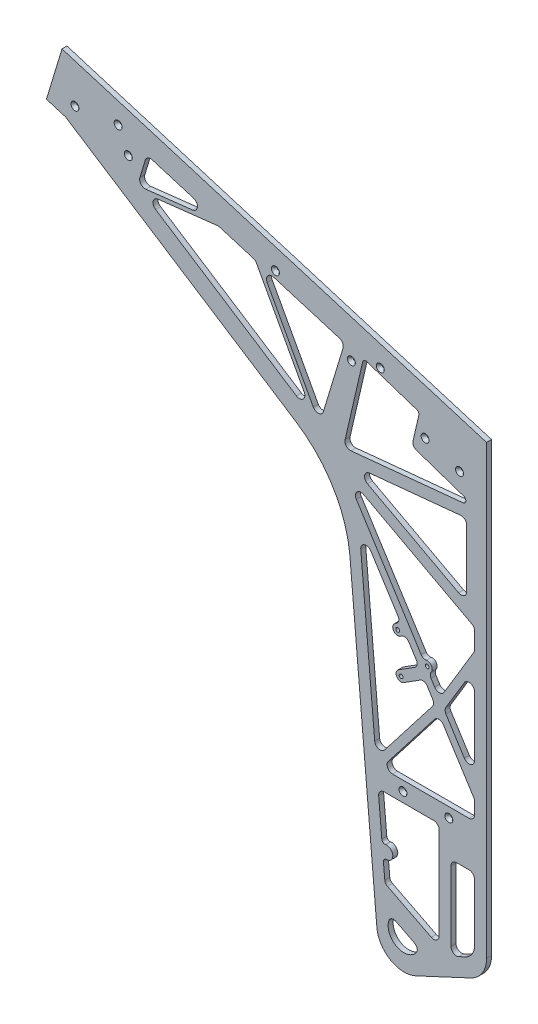
from build123d import *

# Parameters (mm, degrees)
BOSS_EXTRUDE1_DEPTH       = 6.35
BOSS_EXTRUDE3_DEPTH       = 6.35
FILLET2_R                 = 6.35
F_8_CLEARANCE_HOLE1_D     = 4.9149
F_8_CLEARANCE_HOLE1_DEPTH = 6.35
HOLE1_D                   = 3.175
HOLE1_DEPTH               = 31.75
HOLE1_CSINK_D             = 10.16
HOLE1_CSINK_ANGLE         = 82
HOLE1_TIP                 = 0.953866233


with BuildPart() as part:
    # Sketch2 → Boss-Extrude1 (new body)
    with BuildSketch(Plane.XY):
        with BuildLine():
            Line((-35.929687435, 42.153790719), (-1.51387348, -351.220762831))
            ThreePointArc((-1.51387348, -351.220762831), (15.815726351, -378.422785743), (48.038169143, -379.829647978))
            Line((48.038169143, -379.829647978), (118.213861049, -347.106185426))
            ThreePointArc((118.213861049, -347.106185426), (132.909364503, -334.218574785), (138.378918258, -315.453385964))
            Line((138.378918258, -315.453385964), (138.378918258, 254.538122714))
            Line((138.378918258, 254.538122714), (-403.099057101, 418.419278389))
            Line((-403.099057101, 418.419278389), (-422.935039487, 352.879420939))
            Line((-422.935039487, 352.879420939), (-398.624090476, 345.521584423))
            Line((-398.624090476, 345.521584423), (-105.026598758, 156.030008008))
            ThreePointArc((-105.026598758, 156.030008008), (-57.378429325, 107.040440177), (-35.929687435, 42.153790719))
        make_face()
        with BuildLine():
            Line((52.060968117, -347.265819105), (17.052845203, -329.494257158))
            ThreePointArc((17.052845203, -329.494257158), (23.771187013, -359.626780553), (52.060968117, -347.265819105))
        make_face(mode=Mode.SUBTRACT)
        with BuildLine():
            Line((0.727528104, -204.399467425), (4.75858829, -250.474696191))
            ThreePointArc((4.75858829, -250.474696191), (6.172216644, -253.190250993), (9.091990054, -254.110852012))
            Line((9.091990054, -254.110852012), (10.088184752, -254.02369627))
            ThreePointArc((10.088184752, -254.02369627), (18.754988278, -261.296007912), (11.482676636, -269.962811439))
            Line((11.482676636, -269.962811439), (10.486481938, -270.049967182))
            ThreePointArc((10.486481938, -270.049967182), (7.770927136, -271.463595536), (6.850326116, -274.383368945))
            Line((6.850326116, -274.383368945), (8.854908199, -297.295847001))
            Line((8.854908199, -297.295847001), (67.831407622, -327.234741912))
            ThreePointArc((67.831407622, -327.234741912), (74.661956673, -326.958687149), (78, -320.992945508))
            Line((78, -320.992945508), (78, -203.789377226))
            ThreePointArc((78, -203.789377226), (75.949747468, -198.839629758), (71, -196.789377226))
            Line((71, -196.789377226), (7.70089099, -196.789377226))
            ThreePointArc((7.70089099, -196.789377226), (2.539949633, -199.060245773), (0.727528104, -204.399467425))
        make_face(mode=Mode.SUBTRACT)
        with BuildLine():
            Line((123, -309.069613992), (123, -235.789377226))
            ThreePointArc((123, -235.789377226), (120.949747468, -230.839629758), (116, -228.789377226))
            Line((116, -228.789377226), (100, -228.789377226))
            ThreePointArc((100, -228.789377226), (95.050252532, -230.839629758), (93, -235.789377226))
            Line((93, -235.789377226), (93, -324.812449913))
            ThreePointArc((93, -324.812449913), (96.238902742, -330.716190033), (102.958327832, -331.156604422))
            Line((102.958327832, -331.156604422), (111.452365235, -327.195769732))
            ThreePointArc((111.452365235, -327.195769732), (119.867828916, -319.815606158), (123, -309.069613992))
        make_face(mode=Mode.SUBTRACT)
        with BuildLine():
            Line((123, -164.789377226), (123, -147.490950451))
            Line((123, -147.490950451), (83.358453873, -85.049471439))
            ThreePointArc((83.358453873, -85.049471439), (77.778314801, -81.809029579), (71.918165908, -84.510338605))
            Line((71.918165908, -84.510338605), (12.96294892, -160.498446277))
            ThreePointArc((12.96294892, -160.498446277), (12.207227911, -167.868620912), (18.493582843, -171.789377226))
            Line((18.493582843, -171.789377226), (116, -171.789377226))
            ThreePointArc((116, -171.789377226), (120.949747468, -169.739124694), (123, -164.789377226))
        make_face(mode=Mode.SUBTRACT)
        with BuildLine():
            Line((123, -104.746758641), (123, -28.654884494))
            ThreePointArc((123, -28.654884494), (117.87337083, -21.91022129), (110.002719505, -25.044811549))
            Line((110.002719505, -25.044811549), (86.491561629, -64.103027464))
            ThreePointArc((86.491561629, -64.103027464), (85.489337935, -67.796413702), (86.579188082, -71.464898525))
            Line((86.579188082, -71.464898525), (110.090345958, -108.498556757))
            ThreePointArc((110.090345958, -108.498556757), (117.95351244, -111.468647449), (123, -104.746758641))
        make_face(mode=Mode.SUBTRACT)
        with BuildLine():
            Line((-22.088705619, 56.391277374), (-4.323316108, -146.668053908))
            ThreePointArc((-4.323316108, -146.668053908), (0.673303529, -152.773057612), (8.180680701, -150.348894658))
            Line((8.180680701, -150.348894658), (69.309232347, -71.559549091))
            ThreePointArc((69.309232347, -71.559549091), (70.770838401, -67.598133112), (69.688252467, -63.516820026))
            Line((69.688252467, -63.516820026), (-9.20568869, 60.753165689))
            ThreePointArc((-9.20568869, 60.753165689), (-17.360200533, 63.631647617), (-22.088705619, 56.391277374))
        make_face(mode=Mode.SUBTRACT)
        with BuildLine():
            Line((84.107110781, -48.674037444), (123, 15.937279137))
            Line((123, 15.937279137), (123, 42.734746572))
            Line((123, 42.734746572), (-18.511705321, 118.505409967))
            ThreePointArc((-18.511705321, 118.505409967), (-26.945537791, 117.097436807), (-27.725581647, 108.582541028))
            Line((-27.725581647, 108.582541028), (72.200176244, -48.815762615))
            ThreePointArc((72.200176244, -48.815762615), (78.193143579, -52.063468688), (84.107110781, -48.674037444))
        make_face(mode=Mode.SUBTRACT)
        with BuildLine():
            Line((105.313578156, 157.453539643), (-10.929529426, 145.999506934))
            ThreePointArc((-10.929529426, 145.999506934), (-17.10814199, 140.401199203), (-13.547329865, 132.862172762))
            Line((-13.547329865, 132.862172762), (102.695777716, 70.621262326))
            ThreePointArc((102.695777716, 70.621262326), (109.596556966, 70.786937409), (113, 76.792333148))
            Line((113, 76.792333148), (113, 150.487276294))
            ThreePointArc((113, 150.487276294), (110.700800309, 155.67403602), (105.313578156, 157.453539643))
        make_face(mode=Mode.SUBTRACT)
        with BuildLine():
            Line((49.392848873, 246.173011312), (-14.483251541, 267.337792758))
            ThreePointArc((-14.483251541, 267.337792758), (-17.700947347, 267.027913965), (-19.638832994, 264.440600612))
            Line((-19.638832994, 264.440600612), (-42.069101758, 167.284432607))
            ThreePointArc((-42.069101758, 167.284432607), (-40.506252061, 161.088502443), (-34.56208946, 158.743511877))
            Line((-34.56208946, 158.743511877), (108.347619238, 172.825142281))
            ThreePointArc((108.347619238, 172.825142281), (111.928836089, 176.345829111), (109.246803026, 180.591656302))
            Line((109.246803026, 180.591656302), (43.179065741, 203.128952263))
            Line((43.179065741, 203.128952263), (52.032227939, 241.476210731))
            ThreePointArc((52.032227939, 241.476210731), (51.62186525, 244.335609561), (49.392848873, 246.173011312))
        make_face(mode=Mode.SUBTRACT)
        with BuildLine():
            Line((-69.784306523, 184.370032832), (-44.706876204, 267.065219692))
            ThreePointArc((-44.706876204, 267.065219692), (-45.232474987, 272.396943743), (-49.374227682, 275.795387513))
            Line((-49.374227682, 275.795387513), (-133.260879434, 301.234131215))
            ThreePointArc((-133.260879434, 301.234131215), (-140.719592777, 298.956271764), (-141.441685904, 291.190988129))
            Line((-141.441685904, 291.190988129), (-82.632464471, 183.057057567))
            ThreePointArc((-82.632464471, 183.057057567), (-75.771430391, 179.437708203), (-69.784306523, 184.370032832))
        make_face(mode=Mode.SUBTRACT)
        with BuildLine():
            Line((-94.219556595, 193.897215489), (-156.413812467, 308.255290327))
            Line((-156.413812467, 308.255290327), (-203.44724953, 322.518245469))
            Line((-203.44724953, 322.518245469), (-280.850407294, 313.614765043))
            ThreePointArc((-280.850407294, 313.614765043), (-286.86682027, 308.2536194), (-283.849633654, 300.781290939))
            Line((-283.849633654, 300.781290939), (-104.168098154, 184.673502969))
            ThreePointArc((-104.168098154, 184.673502969), (-95.609738272, 185.41962086), (-94.219556595, 193.897215489))
        make_face(mode=Mode.SUBTRACT)
        with BuildLine():
            Line((-235.29053913, 337.399615142), (-288.121603561, 353.420708839))
            ThreePointArc((-288.121603561, 353.420708839), (-293.453327613, 352.895110056), (-296.851771382, 348.753357361))
            Line((-296.851771382, 348.753357361), (-303.795258461, 325.85655517))
            ThreePointArc((-303.795258461, 325.85655517), (-302.470894404, 319.340074867), (-296.296581911, 316.871001979))
            Line((-296.296581911, 316.871001979), (-236.522030401, 323.746710474))
            ThreePointArc((-236.522030401, 323.746710474), (-230.350250816, 330.072008843), (-235.29053913, 337.399615142))
        make_face(mode=Mode.SUBTRACT)
    extrude(amount=BOSS_EXTRUDE1_DEPTH)

    # Sketch3 → Boss-Extrude3 (add, through all)
    with BuildSketch(Plane.XY.offset(6.35)):
        with BuildLine():
            Line((52.31570416, -36.152407776), (25.913952806, -52.913801975))
            ThreePointArc((25.913952806, -52.913801975), (23.956469216, -61.67811929), (32.72078653, -63.63560288))
            Line((32.72078653, -63.63560288), (59.122537885, -46.874208681))
            ThreePointArc((59.122537885, -46.874208681), (61.944204814, -42.766636514), (60.931946749, -37.887160417))
            ThreePointArc((60.931946749, -37.887160417), (58.160882961, -37.10052972), (56.022474066, -35.170558278))
            ThreePointArc((56.022474066, -35.170558278), (54.093204041, -35.374994618), (52.31570416, -36.152407776))
        make_face()
        with BuildLine():
            ThreePointArc((57.83188293, -26.183510014), (55.010216001, -30.291082181), (56.022474066, -35.170558278))
            ThreePointArc((56.022474066, -35.170558278), (58.793537853, -35.957188975), (60.931946749, -37.887160417))
            ThreePointArc((60.931946749, -37.887160417), (62.861216773, -37.682724076), (64.638716654, -36.905310919))
            Line((64.638716654, -36.905310919), (66.052192066, -36.007953079))
            ThreePointArc((66.052192066, -36.007953079), (68.009675656, -27.243635765), (59.245358342, -25.286152174))
            Line((59.245358342, -25.286152174), (57.83188293, -26.183510014))
        make_face()
        with BuildLine():
            Line((28.889634086, 0.747224197), (21.62284071, -3.866166283))
            ThreePointArc((21.62284071, -3.866166283), (19.66535712, -12.630483598), (28.429674435, -14.587967188))
            Line((28.429674435, -14.587967188), (35.69646781, -9.974576708))
            ThreePointArc((35.69646781, -9.974576708), (37.653951401, -1.210259394), (28.889634086, 0.747224197))
        make_face()
    extrude(amount=-BOSS_EXTRUDE3_DEPTH)

    # Fillet2
    fillet2_edges = [part.edges().sort_by_distance(p)[0] for p in [
        (-203.44724953, 322.518245469, 3.175),
        (-156.413812467, 308.255290327, 3.175),
        (43.179065741, 203.128952263, 3.175),
        (123, 42.734746572, 3.175),
        (123, 15.937279137, 3.175),
        (123, -147.490950451, 3.175),
        (8.854908199, -297.295847001, 3.175),
        (52.060968117, -347.265819105, 3.175),
        (17.052845203, -329.494257158, 3.175),
        (64.638716654, -36.905310919, 3.175),
        (57.83188293, -26.183510014, 3.175),
        (28.889634086, 0.747224197, 3.175),
        (35.69646781, -9.974576708, 3.175),
        (52.31570416, -36.152407776, 3.175),
        (59.122537885, -46.874208681, 3.175),
    ]]
    fillet(fillet2_edges, radius=FILLET2_R)

    # #8 Clearance Hole1
    with Locations(Plane.XY.offset(6.35)):
        with Locations((62.648775204, -30.647052627), (29.317369668, -58.274702428), (25.026257572, -9.227066735)):
            Hole(F_8_CLEARANCE_HOLE1_D / 2, depth=F_8_CLEARANCE_HOLE1_DEPTH)

    # Hole1
    with Locations(Plane(origin=(277.286738577, -215.287141225, 6.35), x_dir=(-0.089959629, 0.995945413, 0), z_dir=(0, 0, 1))):
        with Locations((637.870011036, 553.595098153), (52.960474705, 241.752641108), (47.697836423, 183.489834462), (434.459074831, 134.806234549), (453.103621196, 177.188747915), (499.723341091, 267.496267453), (636.071223534, 609.111420407), (609.449424187, 543.22015483), (559.371199386, 359.303721429), (507.038658285, 229.776136946)):
            CounterSinkHole(HOLE1_D / 2, HOLE1_CSINK_D / 2, depth=HOLE1_DEPTH, counter_sink_angle=HOLE1_CSINK_ANGLE)
            with Locations((0, 0, -(HOLE1_DEPTH + HOLE1_TIP / 2))):  # 118° drill point
                Cone(0, HOLE1_D / 2, HOLE1_TIP, mode=Mode.SUBTRACT)


solid = part.part
